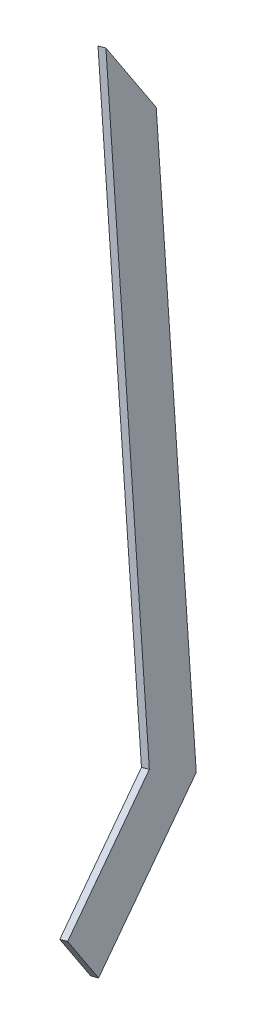
from build123d import *

# Parameters (mm, degrees)
BOSS_EXTRUDE1_DEPTH = 3


with BuildPart() as part:
    # Sketch1 → Boss-Extrude1 (new body)
    with BuildSketch(Plane(origin=(-63.53171022, -8.363863152, 12.725483305), x_dir=(0.233089191, -0.534113538, 0.812645161), z_dir=(0.972455361, 0.128022424, -0.19478406))):
        Polygon((290.734459145, 269.471566891), (290.734459145, 310.078298028), (434.567139603, 494.175733816), (509.260454317, 494.175733816), (509.260454317, 469.175733816), (446.760454317, 469.175733816), align=None)
    extrude(amount=-BOSS_EXTRUDE1_DEPTH)


solid = part.part
